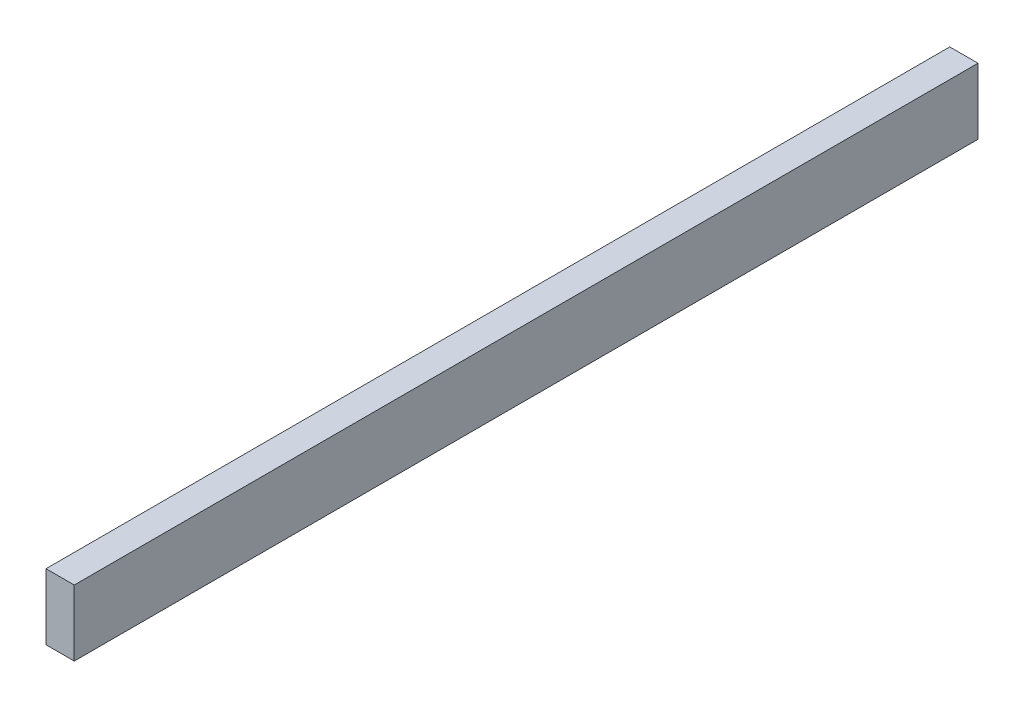
from build123d import *

# Parameters (mm, degrees)
SKETCH1_W           = 38.1
SKETCH1_H           = 88.9
BOSS_EXTRUDE1_DEPTH = 1219.2


with BuildPart() as part:
    # Sketch1 → Boss-Extrude1 (new body)
    with BuildSketch(Plane.XY):
        with Locations((-19.05, 6.816446745)):
            Rectangle(SKETCH1_W, SKETCH1_H)
    extrude(amount=BOSS_EXTRUDE1_DEPTH)


solid = part.part
